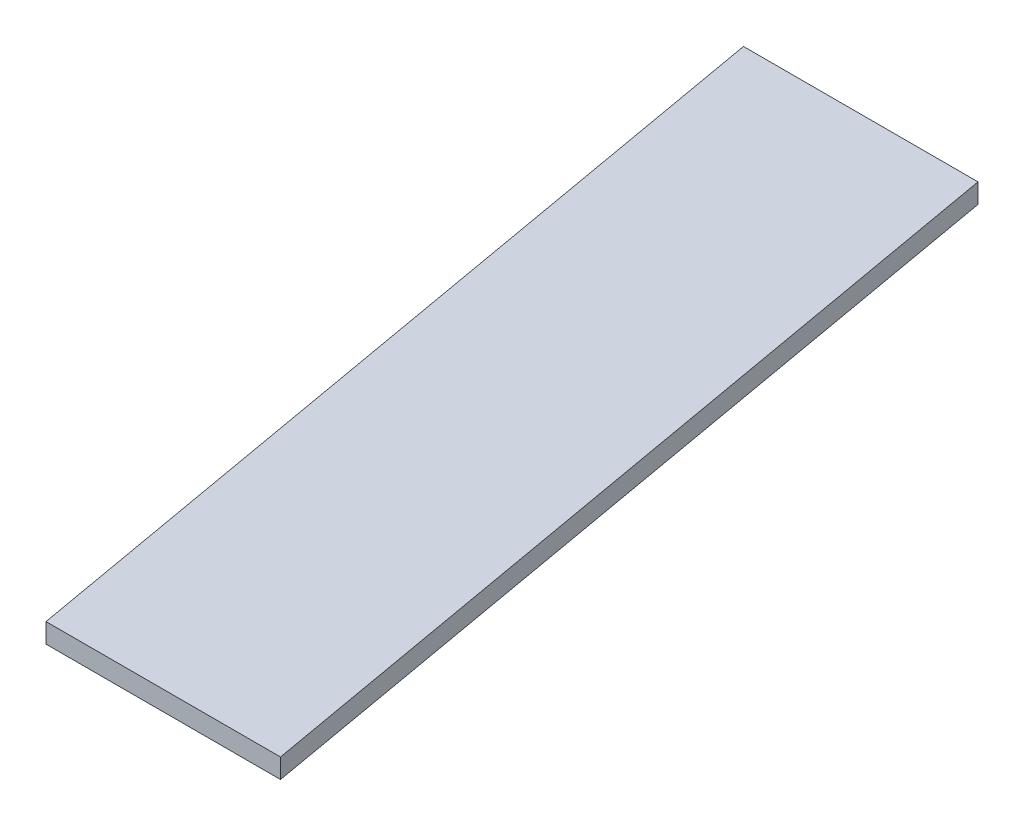
from build123d import *

# Parameters (mm, degrees)
BOSS_EXTRUDE1_DEPTH = 3.175


with BuildPart() as part:
    # Sketch1 → Boss-Extrude1 (new body)
    with BuildSketch(Plane(origin=(0, 0, 0), x_dir=(1, 0, 0), z_dir=(0, 1, 0))):
        Polygon((0, 0), (-24.25865042, 137.577643096), (13.84134958, 137.577643096), (38.1, 0), align=None)
    extrude(amount=BOSS_EXTRUDE1_DEPTH)


solid = part.part
